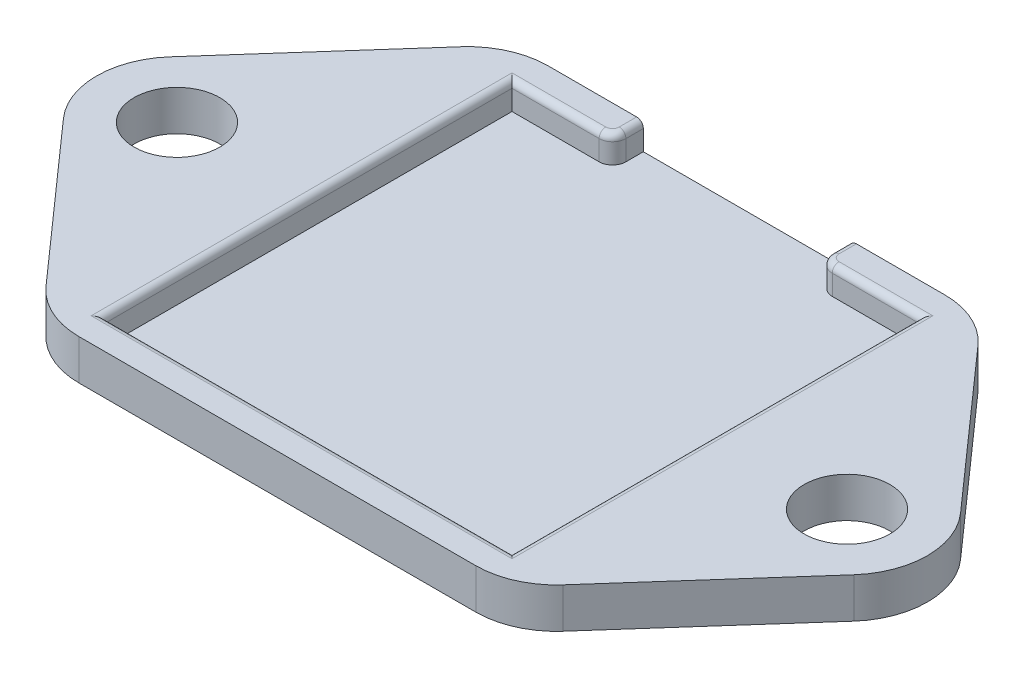
from build123d import *

# Parameters (mm, degrees)
SKETCH1_R           = 3.2
BOSS_EXTRUDE1_DEPTH = 3
CUT_EXTRUDE1_DEPTH  = 2
FILLET1_R           = 6
FILLET2_R           = 1
FILLET3_R           = 0.5


with BuildPart() as part:
    # Sketch1 → Boss-Extrude1 (new body)
    with BuildSketch(Plane(origin=(0, 0, 0), x_dir=(1, 0, 0), z_dir=(0, 1, 0))):
        with BuildLine():
            Line((-17.5, -17.5), (17.5, -17.5))
            Line((17.5, -17.5), (29.489041807, -3.981017917))
            ThreePointArc((29.489041807, -3.981017917), (31, 0), (29.489041807, 3.981017917))
            Line((29.489041807, 3.981017917), (17.5, 17.5))
            Line((17.5, 17.5), (-17.5, 17.5))
            Line((-17.5, 17.5), (-29.489041807, 3.981017917))
            ThreePointArc((-29.489041807, 3.981017917), (-31, 0), (-29.489041807, -3.981017917))
            Line((-29.489041807, -3.981017917), (-17.5, -17.5))
        make_face()
        with Locations((-25, 0)):
            Circle(SKETCH1_R, mode=Mode.SUBTRACT)
        with Locations((25, 0)):
            Circle(SKETCH1_R, mode=Mode.SUBTRACT)
    extrude(amount=BOSS_EXTRUDE1_DEPTH)

    # Sketch2 → Cut-Extrude1 (cut)
    with BuildSketch(Plane(origin=(0, 3, 0), x_dir=(1, 0, 0), z_dir=(0, 1, 0))):
        Polygon((-15.2, 15.2), (-7.7, 15.2), (-7.7, 17.5), (7.7, 17.5), (7.7, 15.2), (15.2, 15.2), (15.2, -15.2), (-15.2, -15.2), align=None)
    extrude(amount=-CUT_EXTRUDE1_DEPTH, mode=Mode.SUBTRACT)

    # Fillet1
    fillet1_edges = [part.edges().sort_by_distance(p)[0] for p in [
        (17.5, 1.5, 17.5),
        (-17.5, 1.5, 17.5),
        (-17.5, 1.5, -17.5),
        (17.5, 1.5, -17.5),
    ]]
    fillet(fillet1_edges, radius=FILLET1_R)

    # Fillet2
    fillet2_edges = [part.edges().sort_by_distance(p)[0] for p in [
        (-7.7, 2, -15.2),
        (7.7, 2, -15.2),
    ]]
    fillet(fillet2_edges, radius=FILLET2_R)

    # Fillet3
    fillet3_edges = [part.edges().sort_by_distance(p)[0] for p in [
        (-11.95, 3, -15.2),
        (-7.992893219, 3, -15.492893219),
        (7.992893219, 3, -15.492893219),
        (15.2, 3, 0),
        (11.95, 3, -15.2),
        (-7.7, 3, -16.85),
        (-15.2, 3, 0),
        (0, 3, 15.2),
        (7.7, 3, -16.85),
    ]]
    fillet(fillet3_edges, radius=FILLET3_R)


solid = part.part
